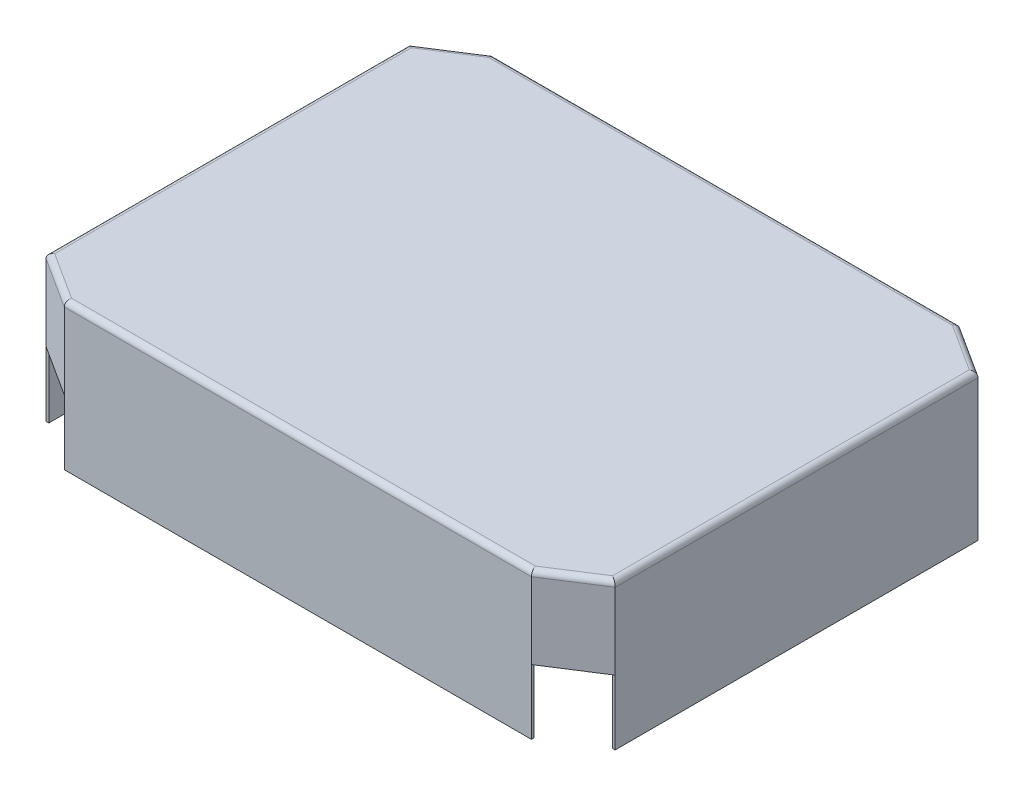
from build123d import *

# Parameters (mm, degrees)
SKETCH1_W             = 210.556721652
SKETCH1_H             = 1.27
BOSS_EXTRUDE1_DEPTH   = 29.21
SKETCH1_W_2           = 1.27
SKETCH1_H_2           = 163.559236
BOSS_EXTRUDE1_2_DEPTH = 29.21
BOSS_EXTRUDE1_3_DEPTH = 29.21
BOSS_EXTRUDE1_4_DEPTH = 29.21
BOSS_EXTRUDE2_DEPTH   = 35.56
BOSS_EXTRUDE3_DEPTH   = 1.27
FILLET1_R             = 2.54


with BuildPart() as part:
    # Sketch1 → Boss-Extrude1 (new body)
    with BuildSketch(Plane(origin=(0, 0, 0), x_dir=(1, 0, 0), z_dir=(0, 1, 0))):
        with Locations((0, -95.885)):
            Rectangle(SKETCH1_W, SKETCH1_H)
    extrude(amount=BOSS_EXTRUDE1_DEPTH)



with BuildPart() as body_2:
    # Sketch1 → Boss-Extrude1 2 (new body)
    with BuildSketch(Plane(origin=(0, 0, 0), x_dir=(1, 0, 0), z_dir=(0, 1, 0))):
        with Locations((-127.635, 0)):
            Rectangle(SKETCH1_W_2, SKETCH1_H_2)
    extrude(amount=BOSS_EXTRUDE1_2_DEPTH)


with BuildPart() as body_3:
    # Sketch1 → Boss-Extrude1 3 (new body)
    with BuildSketch(Plane(origin=(0, 0, 0), x_dir=(1, 0, 0), z_dir=(0, 1, 0))):
        with Locations((0, 95.885)):
            Rectangle(SKETCH1_W, SKETCH1_H)
    extrude(amount=BOSS_EXTRUDE1_3_DEPTH)


with BuildPart() as body_4:
    # Sketch1 → Boss-Extrude1 4 (new body)
    with BuildSketch(Plane(origin=(0, 0, 0), x_dir=(1, 0, 0), z_dir=(0, 1, 0))):
        with Locations((127.635, 0)):
            Rectangle(SKETCH1_W_2, SKETCH1_H_2)
    extrude(amount=BOSS_EXTRUDE1_4_DEPTH)


with BuildPart() as part_1:
    add(part.part)

    add(body_2.part)  # Boss-Extrude2 merges body 2

    add(body_3.part)  # Boss-Extrude2 merges body 3

    add(body_4.part)  # Boss-Extrude2 merges body 4
    # Sketch4 → Boss-Extrude2 (add)
    with BuildSketch(Plane(origin=(0, 29.21, 0), x_dir=(1, 0, 0), z_dir=(0, 1, 0))):
        Polygon((-128.27, 81.779618), (-105.278360826, 96.52), (105.278360826, 96.52), (128.27, 81.779618), (128.27, -81.779618), (105.278360826, -96.52), (-105.278360826, -96.52), (-128.27, -81.779618), align=None)
        Polygon((-127, 81.779618), (-105.278360826, 95.25), (105.278360826, 95.25), (127, 81.779618), (127, -81.779618), (105.278360826, -95.25), (-105.278360826, -95.25), (-127, -81.779618), align=None, mode=Mode.SUBTRACT)
    extrude(amount=BOSS_EXTRUDE2_DEPTH)

    # Sketch5 → Boss-Extrude3 (add)
    with BuildSketch(Plane(origin=(0, 64.77, 0), x_dir=(1, 0, 0), z_dir=(0, 1, 0))):
        Polygon((-128.27, 81.779618), (-105.278360826, 96.52), (105.278360826, 96.52), (128.27, 81.779618), (128.27, -81.779618), (105.278360826, -96.52), (-105.278360826, -96.52), (-128.27, -81.779618), align=None)
    extrude(amount=BOSS_EXTRUDE3_DEPTH)

    # Fillet1
    fillet1_edges = [part_1.edges().sort_by_distance(p)[0] for p in [
        (-128.27, 66.04, 0),
        (-116.774180413, 66.04, 89.149809),
        (0, 66.04, 96.52),
        (116.774180413, 66.04, 89.149809),
        (128.27, 66.04, 0),
        (116.774180413, 66.04, -89.149809),
        (0, 66.04, -96.52),
        (-116.774180413, 66.04, -89.149809),
    ]]
    fillet(fillet1_edges, radius=FILLET1_R)


solid = part_1.part
